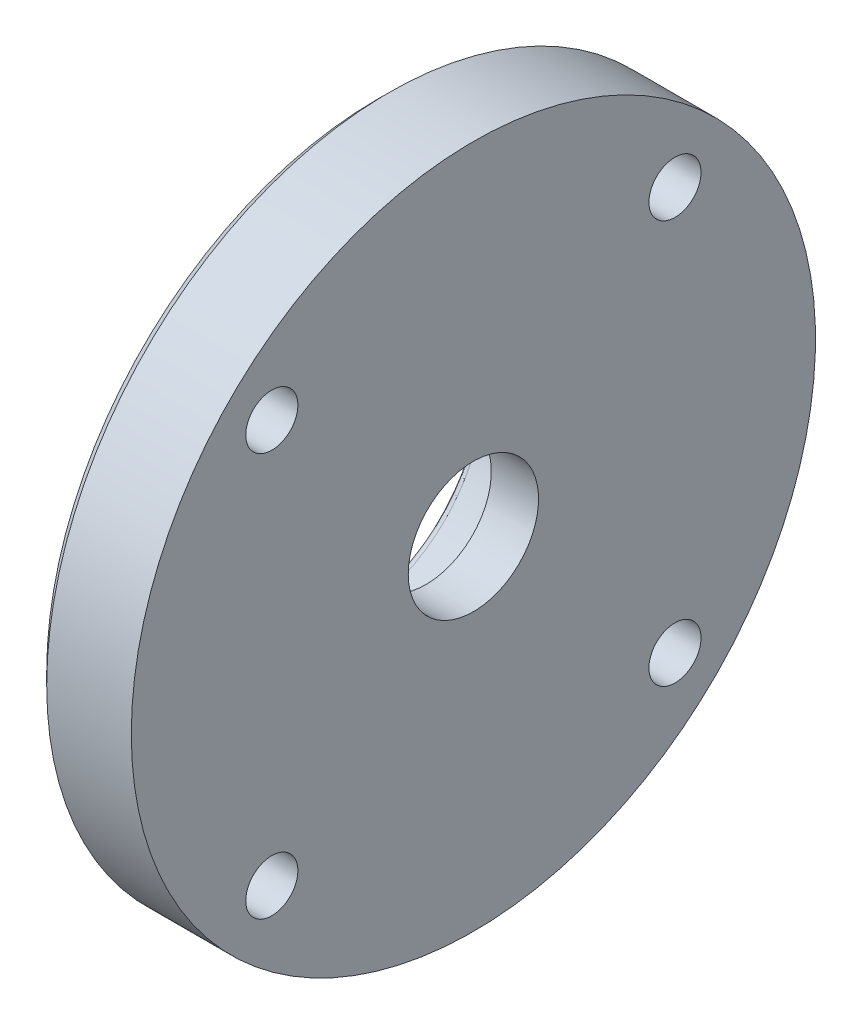
from build123d import *

# Parameters (mm, degrees)
SKETCH2_R           = 8
BOSS_EXTRUDE1_DEPTH = 2
FILLET1_R           = 0.5
SKETCH3_R           = 1.6
CUT_EXTRUDE1_DEPTH  = 10
SKETCH4_R           = 4
CUT_EXTRUDE2_DEPTH  = 10
SKETCH5_R           = 8
CUT_EXTRUDE3_DEPTH  = 3


with BuildPart() as part:
    # Sketch1 → Revolve1 (revolve)
    with BuildSketch(Plane.XY):
        Polygon((0, 0), (0, 20.292893219), (0.707106781, 21), (5.9, 21), (5.9, 0), align=None)
    revolve(axis=Axis((0, 0, 0), (1, 0, 0)))

    # Sketch2 → Boss-Extrude1 (add)
    with BuildSketch(Plane.ZY):
        with BuildLine():
            Line((-11.5, -4.898979486), (-11.5, 4.898979486))
            ThreePointArc((-11.5, 4.898979486), (0, 12.5), (11.5, 4.898979486))
            Line((11.5, 4.898979486), (11.5, -4.898979486))
            ThreePointArc((11.5, -4.898979486), (0, -12.5), (-11.5, -4.898979486))
        make_face()
        Circle(SKETCH2_R, mode=Mode.SUBTRACT)
    extrude(amount=BOSS_EXTRUDE1_DEPTH)

    # Fillet1
    fillet1_edges = [part.edges().sort_by_distance(p)[0] for p in [
        (-2, 12.5, 0),
        (-2, 0, -11.5),
        (-2, -12.5, 0),
        (-2, 0, 11.5),
        (0, 12.5, 0),
        (-1, 4.898979486, 11.5),
        (0, 0, -11.5),
        (-1, 4.898979486, -11.5),
        (0, -12.5, 0),
        (-1, -4.898979486, -11.5),
        (0, 0, 11.5),
        (-1, -4.898979486, 11.5),
        (-2, 0, -8),
    ]]
    fillet(fillet1_edges, radius=FILLET1_R)

    # Sketch3 → Cut-Extrude1 (cut)
    with BuildSketch(Plane.ZY):
        with Locations((12.374368671, 12.374368671)):
            Circle(SKETCH3_R)
        with Locations((-12.374368671, 12.374368671)):
            Circle(SKETCH3_R)
        with Locations((-12.374368671, -12.374368671)):
            Circle(SKETCH3_R)
        with Locations((12.374368671, -12.374368671)):
            Circle(SKETCH3_R)
    extrude(amount=-CUT_EXTRUDE1_DEPTH, mode=Mode.SUBTRACT)

    # Sketch4 → Cut-Extrude2 (cut)
    with BuildSketch(Plane.ZY):
        Circle(SKETCH4_R)
    extrude(amount=-CUT_EXTRUDE2_DEPTH, mode=Mode.SUBTRACT)

    # Sketch5 → Cut-Extrude3 (cut)
    with BuildSketch(Plane.ZY):
        Circle(SKETCH5_R)
    extrude(amount=-CUT_EXTRUDE3_DEPTH, mode=Mode.SUBTRACT)


solid = part.part
